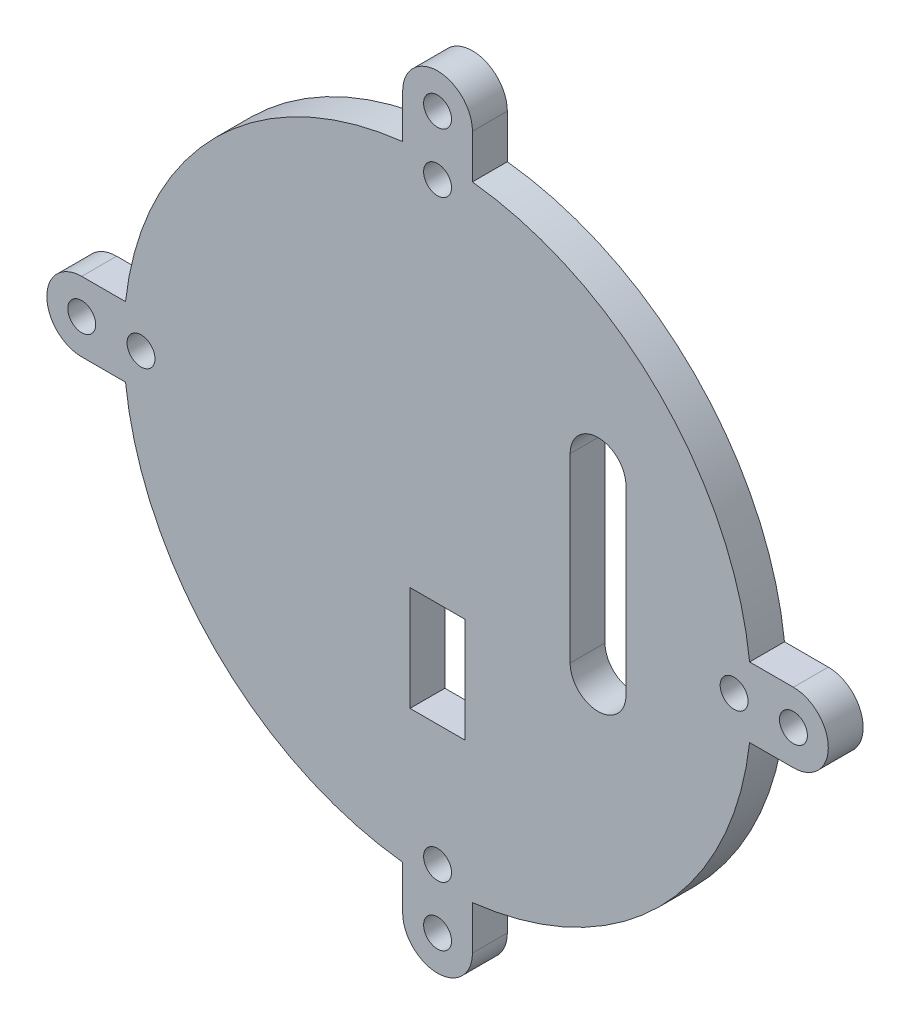
from build123d import *

# Parameters (mm, degrees)
SKETCH1_R           = 2
BOSS_EXTRUDE1_DEPTH = 5
SKETCH2_W           = 7.9
SKETCH2_H           = 15
CUT_EXTRUDE1_DEPTH  = 10
CUT_EXTRUDE2_DEPTH  = 10


with BuildPart() as part:
    # Sketch1 → Boss-Extrude1 (new body)
    with BuildSketch(Plane.XY):
        with BuildLine():
            ThreePointArc((5, 51), (0, 56), (-5, 51))
            Line((-5, 51), (-5, 44.72135955))
            ThreePointArc((-5, 44.72135955), (-31.819805153, 31.819805153), (-44.72135955, 5))
            Line((-44.72135955, 5), (-51, 5))
            ThreePointArc((-51, 5), (-56, 0), (-51, -5))
            Line((-51, -5), (-44.72135955, -5))
            ThreePointArc((-44.72135955, -5), (-31.819805153, -31.819805153), (-5, -44.72135955))
            Line((-5, -44.72135955), (-5, -51))
            ThreePointArc((-5, -51), (0, -56), (5, -51))
            Line((5, -51), (5, -44.72135955))
            ThreePointArc((5, -44.72135955), (31.819805153, -31.819805153), (44.72135955, -5))
            Line((44.72135955, -5), (51, -5))
            ThreePointArc((51, -5), (56, 0), (51, 5))
            Line((51, 5), (44.72135955, 5))
            ThreePointArc((44.72135955, 5), (31.819805153, 31.819805153), (5, 44.72135955))
            Line((5, 44.72135955), (5, 51))
        make_face()
        with Locations((0, 51)):
            Circle(SKETCH1_R, mode=Mode.SUBTRACT)
        with Locations((0, 42.5)):
            Circle(SKETCH1_R, mode=Mode.SUBTRACT)
        with Locations((0, -42.5)):
            Circle(SKETCH1_R, mode=Mode.SUBTRACT)
        with Locations((-42.5, 0)):
            Circle(SKETCH1_R, mode=Mode.SUBTRACT)
        with Locations((42.5, 0)):
            Circle(SKETCH1_R, mode=Mode.SUBTRACT)
        with Locations((51, 0)):
            Circle(SKETCH1_R, mode=Mode.SUBTRACT)
        with Locations((0, -51)):
            Circle(SKETCH1_R, mode=Mode.SUBTRACT)
        with Locations((-51, 0)):
            Circle(SKETCH1_R, mode=Mode.SUBTRACT)
    extrude(amount=BOSS_EXTRUDE1_DEPTH)

    # Sketch2 → Cut-Extrude1 (cut)
    with BuildSketch(Plane(origin=(0, 0, 0), x_dir=(-1, 0, 0), z_dir=(0, 0, -1))):
        with Locations((0, -17.6)):
            Rectangle(SKETCH2_W, SKETCH2_H)
    extrude(amount=-CUT_EXTRUDE1_DEPTH, mode=Mode.SUBTRACT)

    # Sketch3 → Cut-Extrude2 (cut)
    with BuildSketch(Plane(origin=(0, 0, 0), x_dir=(-1, 0, 0), z_dir=(0, 0, -1))):
        with BuildLine():
            Line((-19, 18), (-19, -8))
            ThreePointArc((-19, -8), (-23, -12), (-27, -8))
            Line((-27, -8), (-27, 18))
            ThreePointArc((-27, 18), (-23, 22), (-19, 18))
        make_face()
    extrude(amount=-CUT_EXTRUDE2_DEPTH, mode=Mode.SUBTRACT)


solid = part.part
